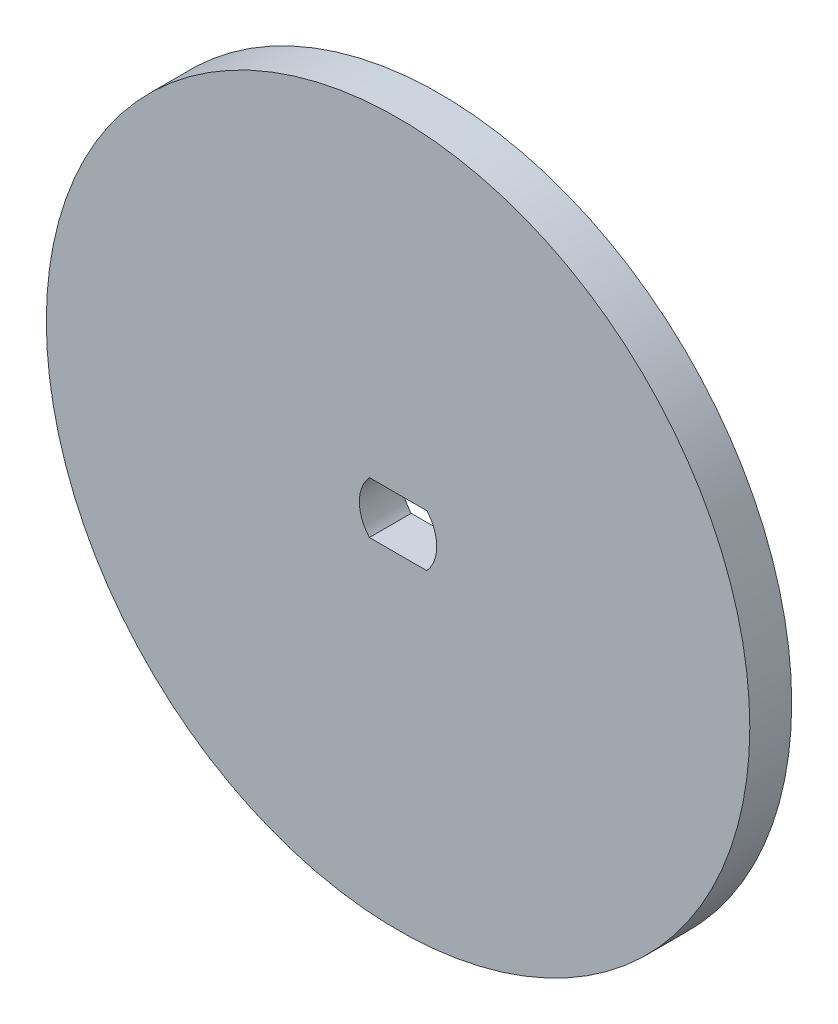
from build123d import *

# Parameters (mm, degrees)
SKETCH1_R           = 26.67
BOSS_EXTRUDE1_DEPTH = 3.175


with BuildPart() as part:
    # Sketch1 → Boss-Extrude1 (new body)
    with BuildSketch(Plane.XY):
        Circle(SKETCH1_R)
        with BuildLine():
            ThreePointArc((-2.175224917, 1.9685), (-2.9337, 0), (-2.175224917, -1.9685))
            Line((-2.175224917, -1.9685), (2.175224917, -1.9685))
            ThreePointArc((2.175224917, -1.9685), (2.9337, 0), (2.175224917, 1.9685))
            Line((2.175224917, 1.9685), (-2.175224917, 1.9685))
        make_face(mode=Mode.SUBTRACT)
    extrude(amount=BOSS_EXTRUDE1_DEPTH)


solid = part.part
